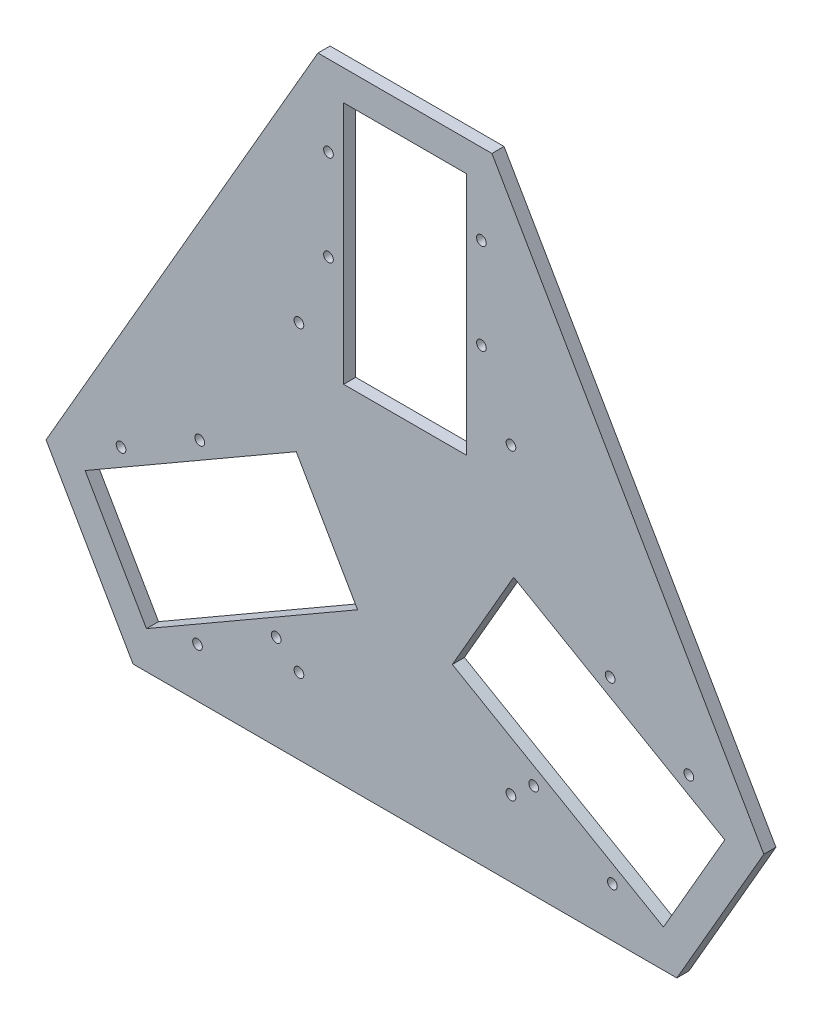
from build123d import *

# Parameters (mm, degrees)
SKETCH_1_R      = 1.6
SKETCH_1_W      = 40.5
SKETCH_1_H      = 80.5
EXTRUDE_1_DEPTH = 4


with BuildPart() as part:
    # ｽｹｯﾁ1 → ﾎﾞｽ - 押し出し1 (new body)
    with BuildSketch(Plane.XY):
        Polygon((-28.723175892, 120.25), (28.723175892, 120.25), (118.501142751, -35.25), (89.777966859, -85), (-89.777966859, -85), (-118.501142751, -35.25), align=None)
        with Locations((25.25, 93.660254038)):
            Circle(SKETCH_1_R, mode=Mode.SUBTRACT)
        with Locations((25.25, 63.660254038)):
            Circle(SKETCH_1_R, mode=Mode.SUBTRACT)
        with Locations((-25.25, 63.660254038)):
            Circle(SKETCH_1_R, mode=Mode.SUBTRACT)
        with Locations((-25.25, 93.660254038)):
            Circle(SKETCH_1_R, mode=Mode.SUBTRACT)
        with Locations((68.487159322, -68.697268464)):
            Circle(SKETCH_1_R, mode=Mode.SUBTRACT)
        with Locations((93.737159322, -24.962985573)):
            Circle(SKETCH_1_R, mode=Mode.SUBTRACT)
        with Locations((67.756397208, -9.962985573)):
            Circle(SKETCH_1_R, mode=Mode.SUBTRACT)
        with Locations((42.506397208, -53.697268464)):
            Circle(SKETCH_1_R, mode=Mode.SUBTRACT)
        with Locations((-93.737159322, -24.962985573)):
            Circle(SKETCH_1_R, mode=Mode.SUBTRACT)
        with Locations((-68.487159322, -68.697268464)):
            Circle(SKETCH_1_R, mode=Mode.SUBTRACT)
        with Locations((-42.506397208, -53.697268464)):
            Circle(SKETCH_1_R, mode=Mode.SUBTRACT)
        with Locations((-67.756397208, -9.962985573)):
            Circle(SKETCH_1_R, mode=Mode.SUBTRACT)
        with Locations((-35, 40)):
            Circle(SKETCH_1_R, mode=Mode.SUBTRACT)
        with Locations((35, 40)):
            Circle(SKETCH_1_R, mode=Mode.SUBTRACT)
        with Locations((35, -60)):
            Circle(SKETCH_1_R, mode=Mode.SUBTRACT)
        with Locations((-35, -60)):
            Circle(SKETCH_1_R, mode=Mode.SUBTRACT)
        with Locations((0, 70)):
            Rectangle(SKETCH_1_W, SKETCH_1_H, mode=Mode.SUBTRACT)
        Polygon((105.604300767, -37.587985573), (85.354300767, -72.662014427), (15.639255763, -32.412014427), (35.889255763, 2.662014427), align=None, mode=Mode.SUBTRACT)
        Polygon((-85.354300767, -72.662014427), (-105.604300767, -37.587985573), (-35.889255763, 2.662014427), (-15.639255763, -32.412014427), align=None, mode=Mode.SUBTRACT)
    extrude(amount=EXTRUDE_1_DEPTH)


solid = part.part
